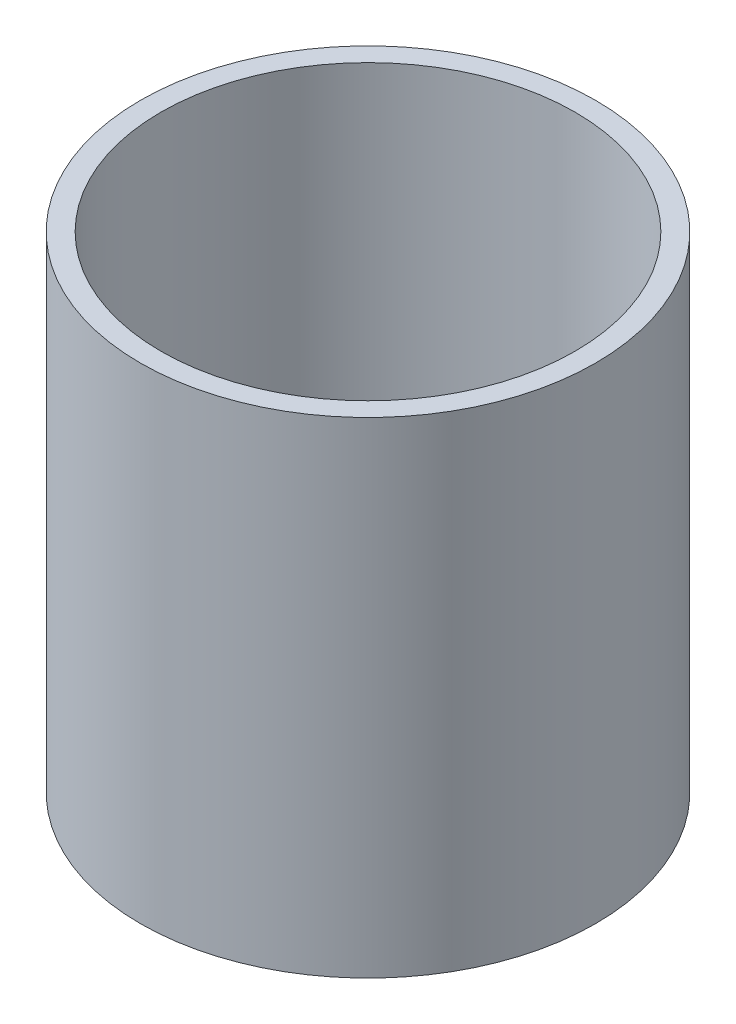
from build123d import *

# Parameters (mm, degrees)
SKETCH1_R           = 19.05
SKETCH1_R_2         = 17.3355
BOSS_EXTRUDE1_DEPTH = 40.64


with BuildPart() as part:
    # Sketch1 → Boss-Extrude1 (new body)
    with BuildSketch(Plane(origin=(0, 0, 0), x_dir=(1, 0, 0), z_dir=(0, 1, 0))):
        Circle(SKETCH1_R)
        Circle(SKETCH1_R_2, mode=Mode.SUBTRACT)
    extrude(amount=BOSS_EXTRUDE1_DEPTH)


solid = part.part
